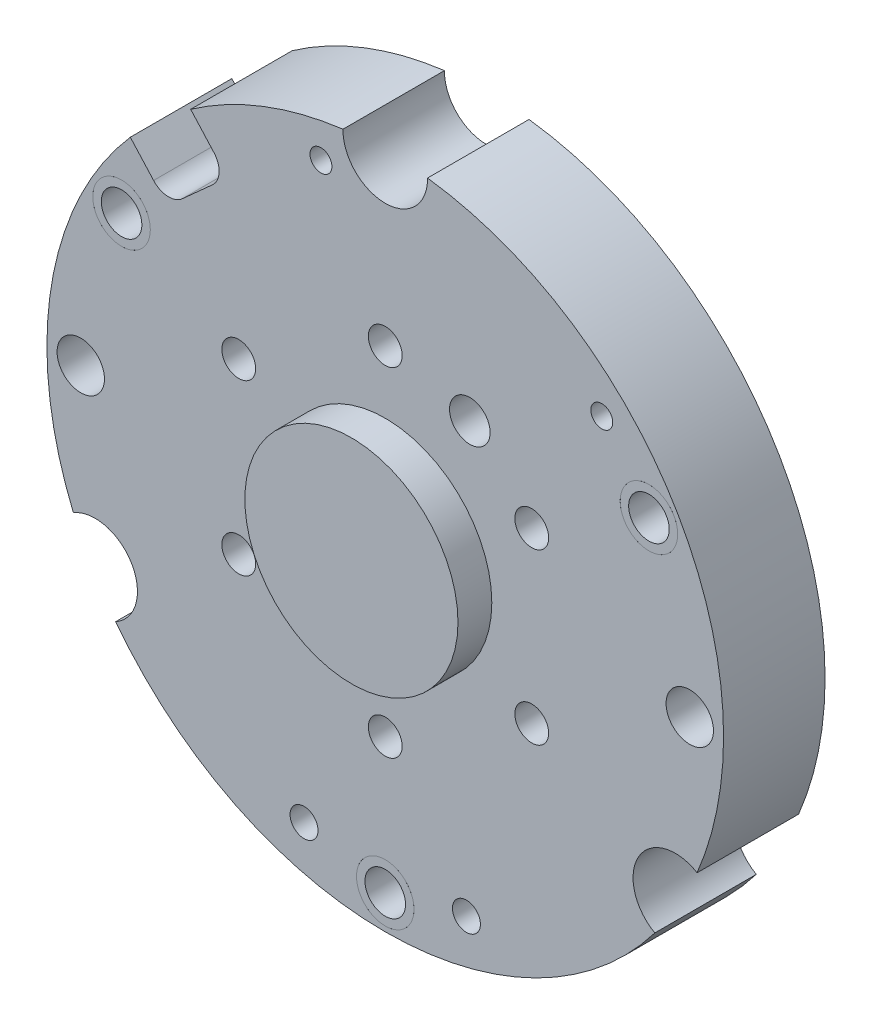
from build123d import *

# Parameters (mm, degrees)
ESTRUSIONE_ESTRUSIONE1_DEPTH   = 15
TAGLIO_ESTRUSIONE1_DEPTH       = 15
SCHIZZO3_R                     = 5.5
TAGLIO_ESTRUSIONE2_DEPTH       = 5
ESTRUSIONE_ESTRUSIONE2_DEPTH   = 5
SCHIZZO6_R                     = 35
TAGLIO_ESTRUSIONE3_DEPTH       = 0.3
SCHIZZO7_R                     = 4.25
SCHIZZO7_R_2                   = 3
ESTRUSIONE_ESTRUSIONE3_DEPTH   = 15
ESTRUSIONE_ESTRUSIONE3_2_DEPTH = 15
ESTRUSIONE_ESTRUSIONE3_3_DEPTH = 15


with BuildPart() as part:
    # Schizzo1 → Estrusione-Estrusione1 (new body)
    with BuildSketch(Plane.XY):
        with BuildLine():
            Line((-34.235180936, 29.055161096), (-37.673638759, 32.873955385))
            ThreePointArc((-37.673638759, 32.873955385), (-49.364560322, 7.946079802), (-46.086634111, -19.391290734))
            ThreePointArc((-46.086634111, -19.391290734), (-37.457286225, -21.625095267), (-39.837731078, -30.215148231))
            ThreePointArc((-39.837731078, -30.215148231), (0, -50), (39.837731078, -30.215148231))
            ThreePointArc((39.837731078, -30.215148231), (37.457286225, -21.625095267), (46.086634111, -19.391290734))
            ThreePointArc((46.086634111, -19.391290734), (43.301043643, 25.000392386), (6.249067596, 49.607954545))
            ThreePointArc((6.249067596, 49.607954545), (0, 43.25), (-6.249067596, 49.607954545))
            ThreePointArc((-6.249067596, 49.607954545), (-18.035485511, 46.633906789), (-28.755900853, 40.903522662))
            Line((-28.755900853, 40.903522662), (-25.31744303, 37.084728372))
            ThreePointArc((-25.31744303, 37.084728372), (-24.550988902, 34.920328684), (-25.539485687, 32.847902076))
            Line((-25.539485687, 32.847902076), (-29.99835464, 28.833118438))
            ThreePointArc((-29.99835464, 28.833118438), (-32.162754328, 28.06666431), (-34.235180936, 29.055161096))
        make_face()
        with BuildLine():
            ThreePointArc((32, 30.379), (33.621, 32), (32, 33.621))
            ThreePointArc((32, 33.621), (30.379, 32), (32, 30.379))
        make_face(mode=Mode.SUBTRACT)
        with BuildLine():
            ThreePointArc((-12, -44.067), (-9.933, -42), (-12, -39.933))
            ThreePointArc((-12, -39.933), (-14.067, -42), (-12, -44.067))
        make_face(mode=Mode.SUBTRACT)
        with BuildLine():
            ThreePointArc((12, -44.067), (14.067, -42), (12, -39.933))
            ThreePointArc((12, -39.933), (9.933, -42), (12, -44.067))
        make_face(mode=Mode.SUBTRACT)
        with BuildLine():
            ThreePointArc((-38.97, 26.75), (-43.22, 22.5), (-38.97, 18.25))
            ThreePointArc((-38.97, 18.25), (-34.72, 22.5), (-38.97, 26.75))
        make_face(mode=Mode.SUBTRACT)
        with BuildLine():
            ThreePointArc((38.97, 26.75), (34.72, 22.5), (38.97, 18.25))
            ThreePointArc((38.97, 18.25), (43.22, 22.5), (38.97, 26.75))
        make_face(mode=Mode.SUBTRACT)
        with BuildLine():
            ThreePointArc((0, -40.75), (-4.25, -45), (0, -49.25))
            ThreePointArc((0, -49.25), (4.25, -45), (0, -40.75))
        make_face(mode=Mode.SUBTRACT)
        with BuildLine():
            ThreePointArc((-45, -3.5), (-41.5, 0), (-45, 3.5))
            ThreePointArc((-45, 3.5), (-48.5, 0), (-45, -3.5))
        make_face(mode=Mode.SUBTRACT)
        with BuildLine():
            ThreePointArc((45, -3.5), (48.5, 0), (45, 3.5))
            ThreePointArc((45, 3.5), (41.5, 0), (45, -3.5))
        make_face(mode=Mode.SUBTRACT)
        with BuildLine():
            ThreePointArc((-9.5, 42.379), (-7.879, 44), (-9.5, 45.621))
            ThreePointArc((-9.5, 45.621), (-11.121, 44), (-9.5, 42.379))
        make_face(mode=Mode.SUBTRACT)
    extrude(amount=ESTRUSIONE_ESTRUSIONE1_DEPTH)

    # Schizzo2 → Taglio-Estrusione1 (cut)
    with BuildSketch(Plane.XY.offset(15)):
        with BuildLine():
            ThreePointArc((-2.165063509, -23.75), (-1.25, -27.165063509), (2.165063509, -26.25))
            ThreePointArc((2.165063509, -26.25), (1.25, -22.834936491), (-2.165063509, -23.75))
        make_face()
        with BuildLine():
            ThreePointArc((19.485571585, -11.25), (20.400635095, -14.665063509), (23.815698604, -13.75))
            ThreePointArc((23.815698604, -13.75), (22.900635095, -10.334936491), (19.485571585, -11.25))
        make_face()
        with BuildLine():
            ThreePointArc((19.485571585, 13.75), (20.400635095, 10.334936491), (23.815698604, 11.25))
            ThreePointArc((23.815698604, 11.25), (22.900635095, 14.665063509), (19.485571585, 13.75))
        make_face()
        with BuildLine():
            ThreePointArc((9.901923789, 23.150635095), (11, 19.052558883), (15.098076211, 20.150635095))
            ThreePointArc((15.098076211, 20.150635095), (14, 24.248711306), (9.901923789, 23.150635095))
        make_face()
        with BuildLine():
            ThreePointArc((-23.815698604, -11.25), (-22.900635095, -14.665063509), (-19.485571585, -13.75))
            ThreePointArc((-19.485571585, -13.75), (-20.400635095, -10.334936491), (-23.815698604, -11.25))
        make_face()
        with BuildLine():
            ThreePointArc((-2.165063509, 26.25), (-1.25, 22.834936491), (2.165063509, 23.75))
            ThreePointArc((2.165063509, 23.75), (1.25, 27.165063509), (-2.165063509, 26.25))
        make_face()
        with BuildLine():
            ThreePointArc((-23.815698604, 13.75), (-22.900635095, 10.334936491), (-19.485571585, 11.25))
            ThreePointArc((-19.485571585, 11.25), (-20.400635095, 14.665063509), (-23.815698604, 13.75))
        make_face()
    extrude(amount=-TAGLIO_ESTRUSIONE1_DEPTH, mode=Mode.SUBTRACT)

    # Schizzo3 → Taglio-Estrusione2 (cut)
    with BuildSketch(Plane(origin=(0, 0, 0), x_dir=(-1, 0, 0), z_dir=(0, 0, -1))):
        with Locations((0, 25)):
            Circle(SCHIZZO3_R)
        with Locations((21.650635095, 12.5)):
            Circle(SCHIZZO3_R)
        with Locations((21.650635095, -12.5)):
            Circle(SCHIZZO3_R)
        with Locations((0, -25)):
            Circle(SCHIZZO3_R)
        with Locations((-21.650635095, -12.5)):
            Circle(SCHIZZO3_R)
        with Locations((-21.650635095, 12.5)):
            Circle(SCHIZZO3_R)
    extrude(amount=-TAGLIO_ESTRUSIONE2_DEPTH, mode=Mode.SUBTRACT)

    # Schizzo6 → Taglio-Estrusione3 (cut)
    with BuildSketch(Plane(origin=(0, 0, 0), x_dir=(-1, 0, 0), z_dir=(0, 0, -1))):
        Circle(SCHIZZO6_R)
    extrude(amount=-TAGLIO_ESTRUSIONE3_DEPTH, mode=Mode.SUBTRACT)


with BuildPart() as body_2:
    # Schizzo5 → Estrusione-Estrusione2 (new body)
    with BuildSketch(Plane.XY.offset(15)):
        with BuildLine():
            ThreePointArc((13.63990011, -7.875), (7.875, 13.63990011), (-13.63990011, 7.875))
            ThreePointArc((-13.63990011, 7.875), (-7.875, -13.63990011), (13.63990011, -7.875))
        make_face()
    extrude(amount=ESTRUSIONE_ESTRUSIONE2_DEPTH)


with BuildPart() as body_3:
    # Schizzo7 → Estrusione-Estrusione3 (new body)
    with BuildSketch(Plane(origin=(0, 0, 0), x_dir=(-1, 0, 0), z_dir=(0, 0, -1))):
        with Locations((38.97, 22.5)):
            Circle(SCHIZZO7_R)
        with Locations((38.97, 22.5)):
            Circle(SCHIZZO7_R_2, mode=Mode.SUBTRACT)
    extrude(amount=-ESTRUSIONE_ESTRUSIONE3_DEPTH)


with BuildPart() as body_4:
    # Schizzo7 → Estrusione-Estrusione3 2 (new body)
    with BuildSketch(Plane(origin=(0, 0, 0), x_dir=(-1, 0, 0), z_dir=(0, 0, -1))):
        with Locations((0, -45)):
            Circle(SCHIZZO7_R)
        with Locations((0, -44.998019971)):
            Circle(SCHIZZO7_R_2, mode=Mode.SUBTRACT)
    extrude(amount=-ESTRUSIONE_ESTRUSIONE3_2_DEPTH)


with BuildPart() as body_5:
    # Schizzo7 → Estrusione-Estrusione3 3 (new body)
    with BuildSketch(Plane(origin=(0, 0, 0), x_dir=(-1, 0, 0), z_dir=(0, 0, -1))):
        with Locations((-38.97, 22.5)):
            Circle(SCHIZZO7_R)
        with Locations((-38.97, 22.5)):
            Circle(SCHIZZO7_R_2, mode=Mode.SUBTRACT)
    extrude(amount=-ESTRUSIONE_ESTRUSIONE3_3_DEPTH)


solid = Compound([part.part, body_2.part, body_3.part, body_4.part, body_5.part])
